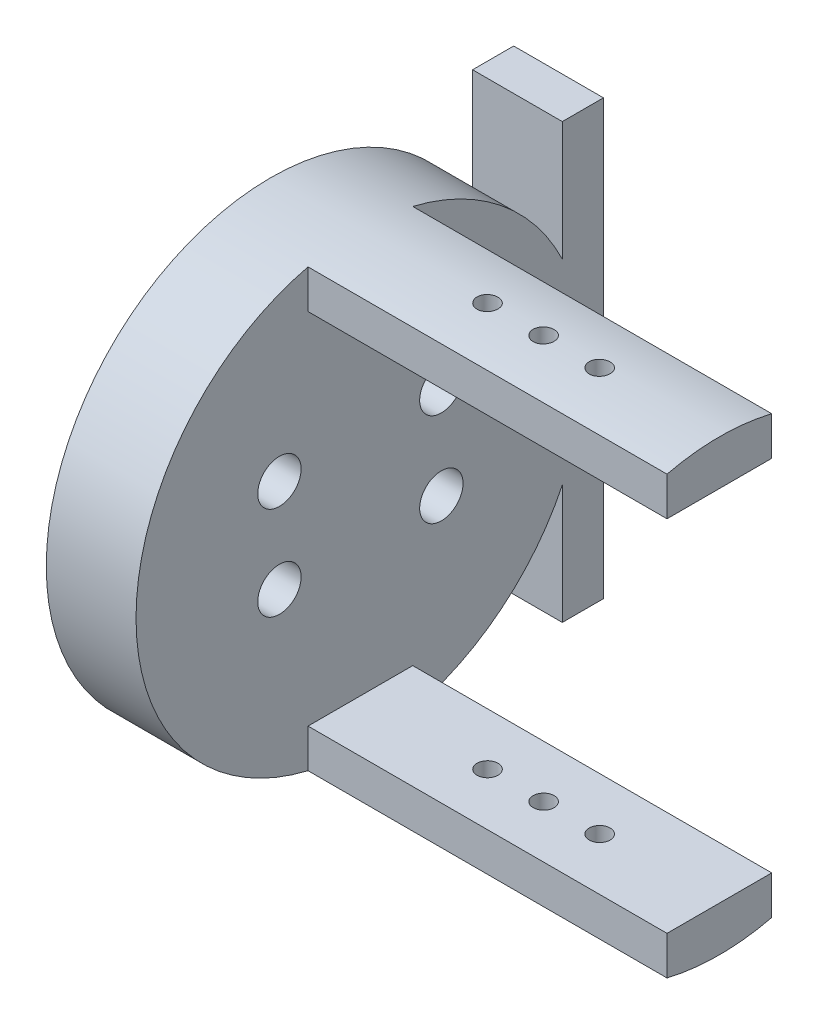
from build123d import *

# Parameters (mm, degrees)
SKETCH_23_R                      = 1.6
SKETCH_23_R_2                    = 2.15
EXTRUDE_9_DEPTH                  = 12
SKETCH_25_R                      = 3.199536645
SKETCH_25_R_2                    = 3.253572192
SKETCH_25_R_3                    = 3.504037636
EXTRUDE_11_DEPTH                 = 8.5
SKETCH_27_R                      = 2.9
CUT_EXTRUDE_14_DEPTH             = 15
CUT_EXTRUDE_14_DEPTH_BACK        = 5
EXTRUDE_14_DEPTH                 = 48
EXTRUDE_14_DEPTH_BACK            = 8.5
EXTRUDE_15_REACH                 = 62
SKETCH_30_R                      = 2.823102459
SKETCH_30_R_2                    = 3.099807243
CUT_EXTRUDE_15_DEPTH             = 38
CUT_EXTRUDE_16_REACH             = 8
SKETCH_33_R                      = 1.4
CUT_EXTRUDE_16_DIRECTION_2_REACH = 56


with BuildPart() as part:
    # 草图23 → 凸台-拉伸9 (new body)
    with BuildSketch(Plane(origin=(10, 0, 0), x_dir=(0, 0, -1), z_dir=(1, 0, 0))):
        with BuildLine():
            Line((32.5, 0), (32.5, 29))
            Line((32.5, 29), (27, 29))
            Line((27, 29), (27, 13.076696831))
            ThreePointArc((27, 13.076696831), (-30, 0), (27, -13.076696831))
            Line((27, -13.076696831), (27, -29))
            Line((27, -29), (32.5, -29))
            Line((32.5, -29), (32.5, 0))
        make_face()
        with Locations((0, 12.5)):
            Circle(SKETCH_23_R, mode=Mode.SUBTRACT)
        with Locations((-10.825317547, 6.25)):
            Circle(SKETCH_23_R, mode=Mode.SUBTRACT)
        with Locations((10.825317547, 6.25)):
            Circle(SKETCH_23_R, mode=Mode.SUBTRACT)
        with Locations((10.825317547, -6.25)):
            Circle(SKETCH_23_R, mode=Mode.SUBTRACT)
        with Locations((0, -12.5)):
            Circle(SKETCH_23_R, mode=Mode.SUBTRACT)
        with Locations((-10.825317547, -6.25)):
            Circle(SKETCH_23_R, mode=Mode.SUBTRACT)
        with Locations((5.1, 8.833459119)):
            Circle(SKETCH_23_R_2, mode=Mode.SUBTRACT)
        with Locations((-10.2, 0)):
            Circle(SKETCH_23_R_2, mode=Mode.SUBTRACT)
        with Locations((5.1, -8.833459119)):
            Circle(SKETCH_23_R_2, mode=Mode.SUBTRACT)
    extrude(amount=-EXTRUDE_9_DEPTH)

    # 草图25 → 凸台-拉伸11 (add)
    with BuildSketch(Plane(origin=(10, 0, 0), x_dir=(0, 0, -1), z_dir=(1, 0, 0))):
        with Locations((5.1, 8.833459119)):
            Circle(SKETCH_25_R)
        with Locations((-10.2, 0)):
            Circle(SKETCH_25_R_2)
        with Locations((5.1, -8.833459119)):
            Circle(SKETCH_25_R_3)
    extrude(amount=-EXTRUDE_11_DEPTH)

    # 草图27 → 切除-拉伸14 (cut, two sides)
    with BuildSketch(Plane(origin=(10, 0, 0), x_dir=(0, 0, -1), z_dir=(1, 0, 0))) as cut_extrude_14_sk:
        with Locations((0, 12.5)):
            Circle(SKETCH_27_R)
        with Locations((-86.65969357, 123.729949726)):
            Circle(SKETCH_27_R)
        with Locations((-33.661578231, 254.394420705)):
            Circle(SKETCH_27_R)
        with Locations((105.996230679, 273.828941958)):
            Circle(SKETCH_27_R)
        with Locations((192.655924249, 162.598992232)):
            Circle(SKETCH_27_R)
        with Locations((139.657808909, 31.934521253)):
            Circle(SKETCH_27_R)
        with Locations((10.825317547, 6.25)):
            Circle(SKETCH_27_R)
        with Locations((10.825317547, -6.25)):
            Circle(SKETCH_27_R)
        with Locations((0, -12.5)):
            Circle(SKETCH_27_R)
        with Locations((-10.825317547, -6.25)):
            Circle(SKETCH_27_R)
        with Locations((-10.825317547, 6.25)):
            Circle(SKETCH_27_R)
    extrude(amount=CUT_EXTRUDE_14_DEPTH, mode=Mode.SUBTRACT)
    extrude(cut_extrude_14_sk.sketch, amount=-CUT_EXTRUDE_14_DEPTH_BACK, mode=Mode.SUBTRACT)

    # 草图29 → 凸台-拉伸14 (add, two sides)
    with BuildSketch(Plane(origin=(10, 0, 0), x_dir=(0, 0, -1), z_dir=(1, 0, 0))) as extrude_14_sk:
        with BuildLine():
            Line((-7, 29.171904292), (-7, -29.171904292))
            ThreePointArc((-7, -29.171904292), (0, -30), (7, -29.171904292))
            Line((7, -29.171904292), (7, 29.171904292))
            ThreePointArc((7, 29.171904292), (0, 30), (-7, 29.171904292))
        make_face()
    extrude(amount=EXTRUDE_14_DEPTH)
    extrude(extrude_14_sk.sketch, amount=-EXTRUDE_14_DEPTH_BACK)

    # 草图30 → 凸台-拉伸15 (add, up to next)
    with BuildSketch(Plane.ZY.offset(2), mode=Mode.PRIVATE) as extrude_15_sk1:
        with Locations((0, 12.5)):
            Circle(SKETCH_30_R)
    extrude_15_tool1 = extrude(extrude_15_sk1.sketch, amount=-EXTRUDE_15_REACH, mode=Mode.PRIVATE) - part.part
    add(extrude_15_tool1.solids().sort_by_distance((-2, 12.5, 0))[0])
    # 草图30 → 凸台-拉伸15 (add, up to next)
    with BuildSketch(Plane.ZY.offset(2), mode=Mode.PRIVATE) as extrude_15_sk2:
        with Locations((0, -12.5)):
            Circle(SKETCH_30_R_2)
    extrude_15_tool2 = extrude(extrude_15_sk2.sketch, amount=-EXTRUDE_15_REACH, mode=Mode.PRIVATE) - part.part
    add(extrude_15_tool2.solids().sort_by_distance((-2, -12.5, 0))[0])

    # 草图32 → 切除-拉伸15 (cut, through all)
    with BuildSketch(Plane(origin=(0, 0, -7), x_dir=(-1, 0, 0), z_dir=(0, 0, -1))):
        Polygon((-58, 0), (-58, 24), (-10, 24), (-10, -24), (-58, -24), align=None)
    extrude(amount=-CUT_EXTRUDE_15_DEPTH, mode=Mode.SUBTRACT)

    # 草图33 → 切除-拉伸16 (cut, up to next)
    with BuildSketch(Plane(origin=(0, -24, 0), x_dir=(1, 0, 0), z_dir=(0, 1, 0)), mode=Mode.PRIVATE) as cut_extrude_16_sk1:
        with Locations((34.5, 0)):
            Circle(SKETCH_33_R)
    cut_extrude_16_tool1 = extrude(cut_extrude_16_sk1.sketch, amount=-CUT_EXTRUDE_16_REACH, mode=Mode.PRIVATE) & part.part
    add(cut_extrude_16_tool1.solids().sort_by_distance((34.5, -24, 0))[0], mode=Mode.SUBTRACT)
    # 草图33 → 切除-拉伸16 (cut, up to next)
    with BuildSketch(Plane(origin=(0, -24, 0), x_dir=(1, 0, 0), z_dir=(0, 1, 0)), mode=Mode.PRIVATE) as cut_extrude_16_sk2:
        with Locations((42, 0)):
            Circle(SKETCH_33_R)
    cut_extrude_16_tool2 = extrude(cut_extrude_16_sk2.sketch, amount=-CUT_EXTRUDE_16_REACH, mode=Mode.PRIVATE) & part.part
    add(cut_extrude_16_tool2.solids().sort_by_distance((42, -24, 0))[0], mode=Mode.SUBTRACT)
    # 草图33 → 切除-拉伸16 (cut, up to next)
    with BuildSketch(Plane(origin=(0, -24, 0), x_dir=(1, 0, 0), z_dir=(0, 1, 0)), mode=Mode.PRIVATE) as cut_extrude_16_sk3:
        with Locations((27, 0)):
            Circle(SKETCH_33_R)
    cut_extrude_16_tool3 = extrude(cut_extrude_16_sk3.sketch, amount=-CUT_EXTRUDE_16_REACH, mode=Mode.PRIVATE) & part.part
    add(cut_extrude_16_tool3.solids().sort_by_distance((27, -24, 0))[0], mode=Mode.SUBTRACT)

    # 草图33 → 切除-拉伸16 direction 2 (cut, up to next)
    with BuildSketch(Plane(origin=(0, -24, 0), x_dir=(1, 0, 0), z_dir=(0, 1, 0)), mode=Mode.PRIVATE) as cut_extrude_16_direction_2_sk1:
        with Locations((34.5, 0)):
            Circle(SKETCH_33_R)
    cut_extrude_16_direction_2_tool1 = extrude(cut_extrude_16_direction_2_sk1.sketch, amount=CUT_EXTRUDE_16_DIRECTION_2_REACH, mode=Mode.PRIVATE) & part.part
    add(cut_extrude_16_direction_2_tool1.solids().sort_by_distance((34.5, -24, 0))[0], mode=Mode.SUBTRACT)
    # 草图33 → 切除-拉伸16 direction 2 (cut, up to next)
    with BuildSketch(Plane(origin=(0, -24, 0), x_dir=(1, 0, 0), z_dir=(0, 1, 0)), mode=Mode.PRIVATE) as cut_extrude_16_direction_2_sk2:
        with Locations((42, 0)):
            Circle(SKETCH_33_R)
    cut_extrude_16_direction_2_tool2 = extrude(cut_extrude_16_direction_2_sk2.sketch, amount=CUT_EXTRUDE_16_DIRECTION_2_REACH, mode=Mode.PRIVATE) & part.part
    add(cut_extrude_16_direction_2_tool2.solids().sort_by_distance((42, -24, 0))[0], mode=Mode.SUBTRACT)
    # 草图33 → 切除-拉伸16 direction 2 (cut, up to next)
    with BuildSketch(Plane(origin=(0, -24, 0), x_dir=(1, 0, 0), z_dir=(0, 1, 0)), mode=Mode.PRIVATE) as cut_extrude_16_direction_2_sk3:
        with Locations((27, 0)):
            Circle(SKETCH_33_R)
    cut_extrude_16_direction_2_tool3 = extrude(cut_extrude_16_direction_2_sk3.sketch, amount=CUT_EXTRUDE_16_DIRECTION_2_REACH, mode=Mode.PRIVATE) & part.part
    add(cut_extrude_16_direction_2_tool3.solids().sort_by_distance((27, -24, 0))[0], mode=Mode.SUBTRACT)


solid = part.part
